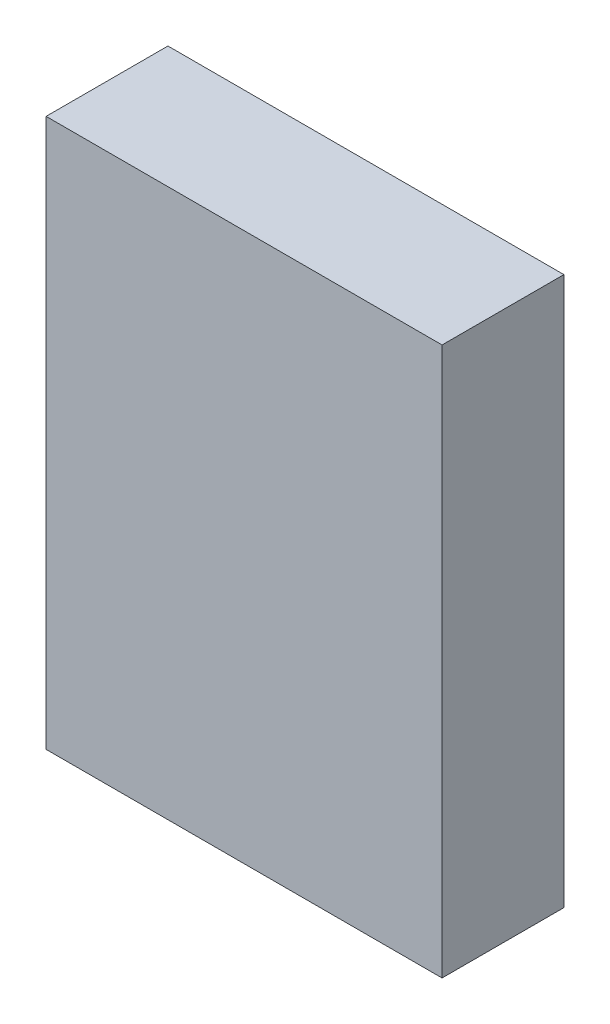
from build123d import *

# Parameters (mm, degrees)
ESQUISSE1_W        = 19.5
ESQUISSE1_H        = 27
BOSS_EXTRU_1_DEPTH = 6


with BuildPart() as part:
    # Esquisse1 → Boss.-Extru.1 (new body)
    with BuildSketch(Plane.XY):
        with Locations((4.087078652, -2.654494382)):
            Rectangle(ESQUISSE1_W, ESQUISSE1_H)
    extrude(amount=BOSS_EXTRU_1_DEPTH)


solid = part.part
